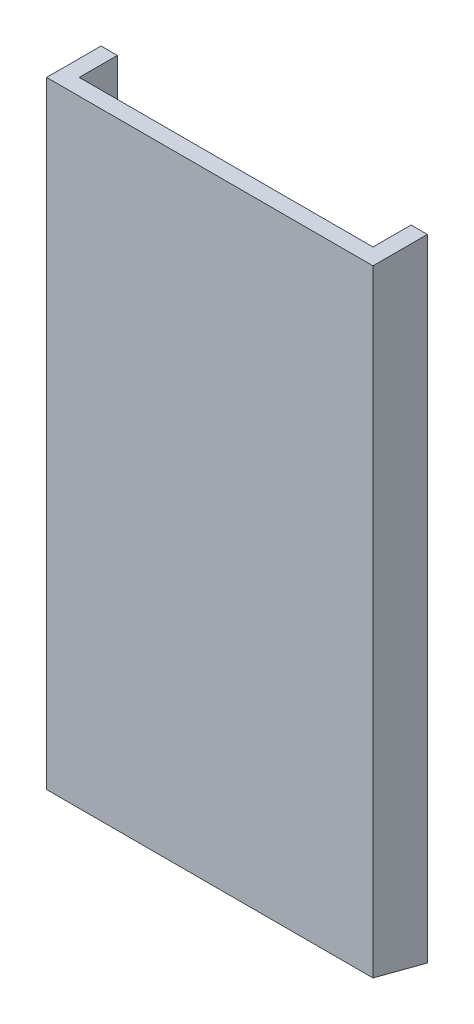
from build123d import *

# Parameters (mm, degrees)
EXTRUDE_1_DEPTH     = 58
EXTRUDE_2_DEPTH     = 1.5
SKETCH_3_R          = 1.55
CUT_EXTRUDE_1_DEPTH = 1.5
CUT_EXTRUDE_2_DEPTH = 31


with BuildPart() as part:
    # 草图1 → 凸台-拉伸1 (new body)
    with BuildSketch(Plane(origin=(0, 0, 0), x_dir=(1, 0, 0), z_dir=(0, 1, 0))):
        Polygon((-15, 0), (15, 0), (15, 5), (13.5, 5), (13.5, 1.5), (-13.5, 1.5), (-13.5, 5), (-15, 5), align=None)
    extrude(amount=EXTRUDE_1_DEPTH)

    # 草图4 → 切除-拉伸2 (cut, through all)
    with BuildSketch(Plane.ZY.offset(15)):
        Polygon((-5, 0), (0, 1.305091324), (0, 0), align=None)
    extrude(amount=-CUT_EXTRUDE_2_DEPTH, mode=Mode.SUBTRACT)


with BuildPart() as body_2:
    # 草图2 → 凸台-拉伸2 (new body)
    with BuildSketch(Plane.ZY.offset(15)):
        with BuildLine():
            Line((-5, 12), (-13.364048259, 8.639539211))
            ThreePointArc((-13.364048259, 8.639539211), (-16.409057753, 3.050709753), (-11.5, -1))
            Line((-11.5, -1), (-5, 0))
            Line((-5, 0), (-5, 12))
        make_face()
    extrude(amount=-EXTRUDE_2_DEPTH)

    # 草图3 → 切除-拉伸1 (cut)
    with BuildSketch(Plane(origin=(-13.5, 0, 0), x_dir=(0, 0, -1), z_dir=(1, 0, 0))):
        with Locations((11.5, 4)):
            Circle(SKETCH_3_R)
    extrude(amount=-CUT_EXTRUDE_1_DEPTH, mode=Mode.SUBTRACT)


solid = Compound([part.part, body_2.part])
